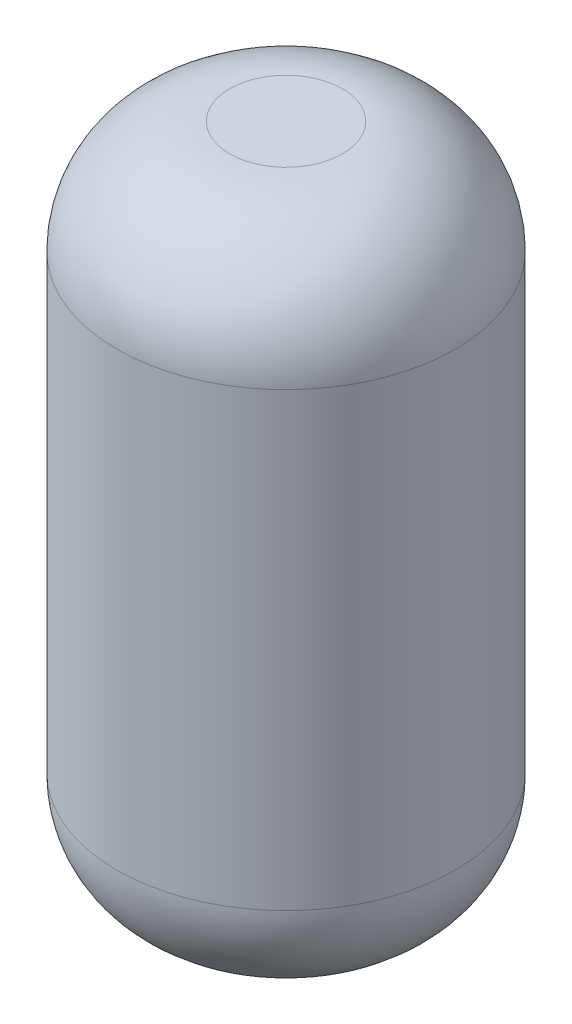
from build123d import *

# Parameters (mm, degrees)
SKETCH2_R          = 9.525
BASE_EXTRUDE_DEPTH = 38.1
FILLET1_R          = 6.35


with BuildPart() as part:
    # Sketch2 → Base-Extrude (new body)
    with BuildSketch(Plane(origin=(0, 0, 0), x_dir=(1, 0, 0), z_dir=(0, 1, 0))):
        Circle(SKETCH2_R)
    extrude(amount=BASE_EXTRUDE_DEPTH)

    # Fillet1
    fillet1_edges = [part.edges().sort_by_distance(p)[0] for p in [
        (-9.525, 0, 0),
        (-9.525, 38.1, 0),
    ]]
    fillet(fillet1_edges, radius=FILLET1_R)


solid = part.part
